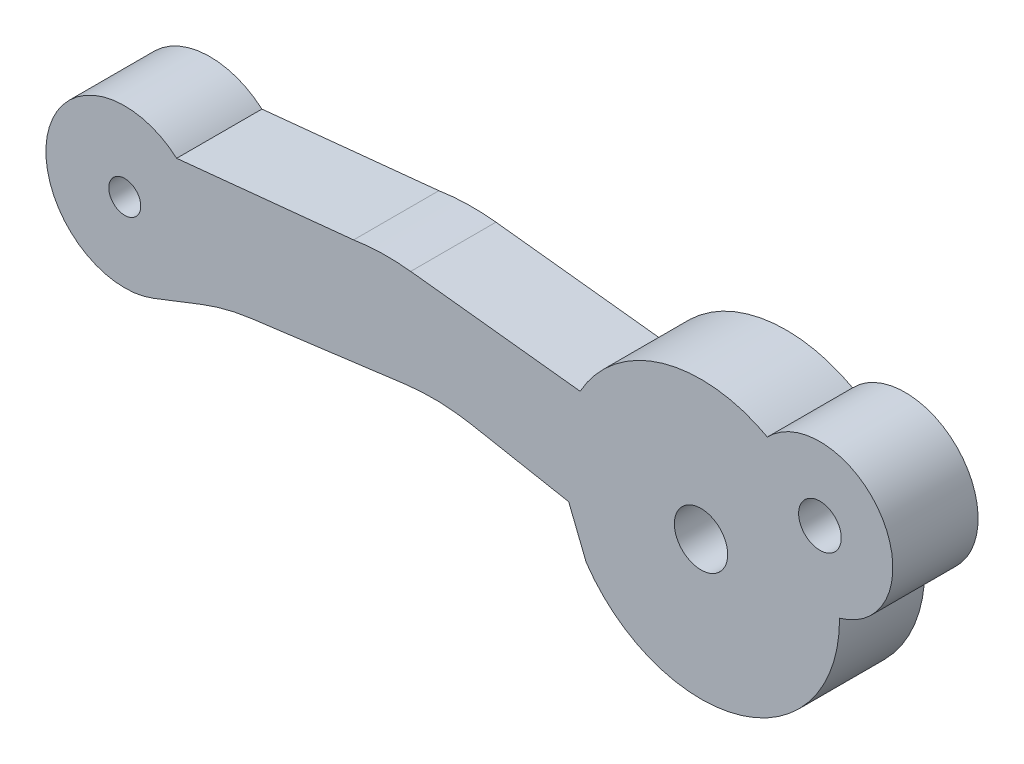
from build123d import *

# Parameters (mm, degrees)
SKETCH1_R           = 0.75
SKETCH1_R_2         = 1.25
SKETCH1_R_3         = 1
BOSS_EXTRUDE2_DEPTH = 4


with BuildPart() as part:
    # Sketch1 → Boss-Extrude2 (new body)
    with BuildSketch(Plane.XY):
        with BuildLine():
            Line((18.405783089, -9.376058657), (25.628644526, -8.435404146))
            ThreePointArc((25.628644526, -8.435404146), (27.202023368, -8.355640481), (28.768404416, -8.523966464))
            Line((28.768404416, -8.523966464), (33.299022581, -9.376058657))
            Line((33.299022581, -9.376058657), (34.120905067, -11.430554242))
            ThreePointArc((34.120905067, -11.430554242), (41.429155101, -14.002085417), (46.007385343, -7.752037497))
            ThreePointArc((46.007385343, -7.752037497), (48.022828461, -2.701791829), (42.620210155, -2.0863995))
            ThreePointArc((42.620210155, -2.0863995), (37.707004122, -1.546981728), (33.834920639, -4.619038785))
            Line((33.834920639, -4.619038785), (25.885206346, -3.723470434))
            ThreePointArc((25.885206346, -3.723470434), (24.544626829, -3.66305828), (23.20802923, -3.782682405))
            Line((23.20802923, -3.782682405), (14.904254879, -4.619038785))
            ThreePointArc((14.904254879, -4.619038785), (8.82513363, -6.767310768), (13.813095481, -10.852775766))
            Line((13.813095481, -10.852775766), (16.06646506, -9.974716914))
            ThreePointArc((16.06646506, -9.974716914), (17.21798795, -9.604519035), (18.405783089, -9.376058657))
        make_face()
        with Locations((12.469720998, -7.405262894)):
            Circle(SKETCH1_R, mode=Mode.SUBTRACT)
        with Locations((39.507512119, -7.792633892)):
            Circle(SKETCH1_R_2, mode=Mode.SUBTRACT)
        with Locations((45.086512481, -4.457254609)):
            Circle(SKETCH1_R_3, mode=Mode.SUBTRACT)
    extrude(amount=BOSS_EXTRUDE2_DEPTH)


solid = part.part
